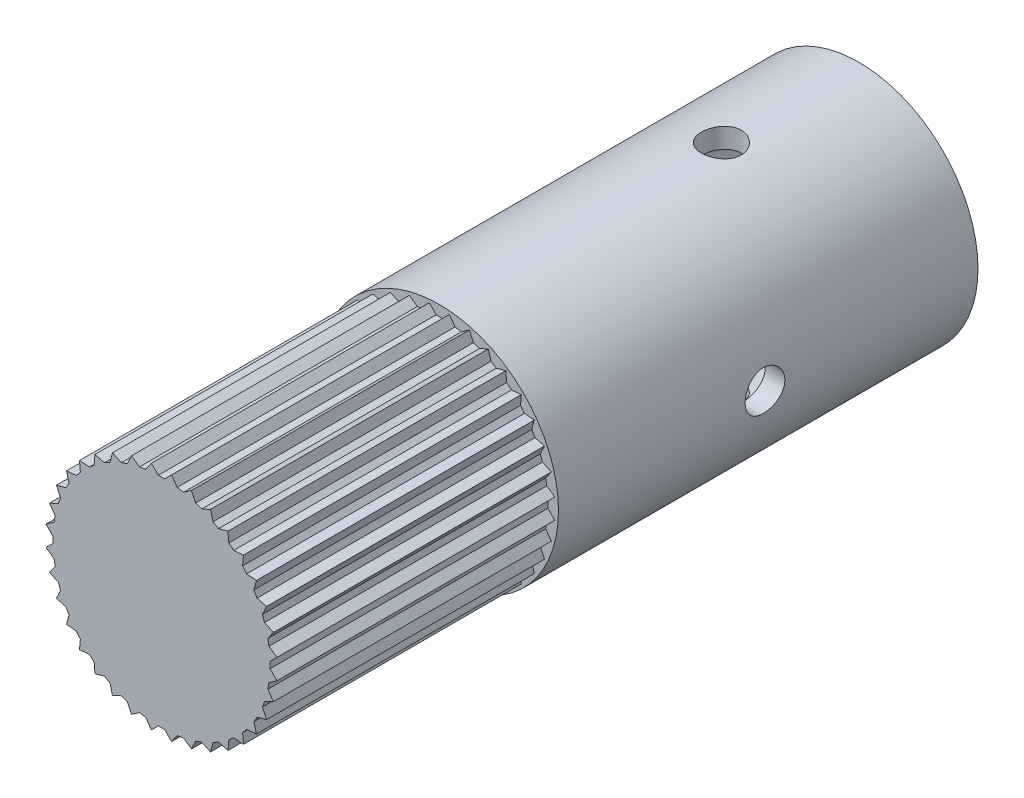
from build123d import *

# Parameters (mm, degrees)
SKETCH5_W               = 1.587499994
SKETCH5_H               = 55.780081988
SKETCH7_R               = 1.5875
CUT_EXTRUDE5_DEPTH      = 10.524999994
CUT_EXTRUDE5_DEPTH_BACK = 10.524999994
SKETCH6_R               = 1.5875
CUT_EXTRUDE6_DEPTH      = 10.525000094
CUT_EXTRUDE6_DEPTH_BACK = 10.525000094
CUT_EXTRUDE7_START      = 77.941582
SKETCH8_R               = 12.7
CUT_EXTRUDE7_DEPTH      = 22.225
SKETCH10_R              = 7.9375
BOSS_EXTRUDE1_DEPTH     = 30.380082


with BuildPart() as part:
    # Sketch5 → Revolve2 (revolve)
    with BuildSketch(Plane(origin=(0, 0, 0), x_dir=(1, 0, 0), z_dir=(0, 1, 0))):
        with Locations((8.731249997, -50.051540994)):
            Rectangle(SKETCH5_W, SKETCH5_H)
    revolve(axis=Axis((0, 0, 0), (0, 0, 1)))

    # Sketch7 → Cut-Extrude5 (cut, two sides)
    with BuildSketch(Plane(origin=(0, 0, 0), x_dir=(0, 0, -1), z_dir=(1, 0, 0))) as cut_extrude5_sk:
        with Locations((-39.195999993, 0)):
            Circle(SKETCH7_R)
    extrude(amount=CUT_EXTRUDE5_DEPTH, mode=Mode.SUBTRACT)
    extrude(cut_extrude5_sk.sketch, amount=-CUT_EXTRUDE5_DEPTH_BACK, mode=Mode.SUBTRACT)

    # Sketch6 → Cut-Extrude6 (cut, two sides)
    with BuildSketch(Plane(origin=(0, 0, 0), x_dir=(1, 0, 0), z_dir=(0, 1, 0))) as cut_extrude6_sk:
        with Locations((1e-09, -33.163499999)):
            Circle(SKETCH6_R)
    extrude(amount=CUT_EXTRUDE6_DEPTH, mode=Mode.SUBTRACT)
    extrude(cut_extrude6_sk.sketch, amount=-CUT_EXTRUDE6_DEPTH_BACK, mode=Mode.SUBTRACT)

    # Sketch8 → Cut-Extrude7 (cut)
    with BuildSketch(Plane.XY.offset(CUT_EXTRUDE7_START)):
        Circle(SKETCH8_R)
        Polygon((9.235721046, -0.808020891), (8.681700155, -0.254), (8.681700155, 0.254), (9.235721046, 0.808020891), (8.593912259, 1.257420242), (8.505698985, 1.75770258), (8.955098336, 2.399511367), (8.245002688, 2.730634406), (8.071256455, 3.207998257), (8.402379494, 3.918093905), (7.645572882, 4.120879625), (7.391572882, 4.56082053), (7.594358603, 5.317627141), (6.813836213, 5.385914002), (6.487300108, 5.775064579), (6.555586968, 6.555586968), (5.775064579, 6.487300108), (5.385914002, 6.813836213), (5.317627141, 7.594358603), (4.56082053, 7.391572882), (4.120879625, 7.645572882), (3.918093905, 8.402379494), (3.207998257, 8.071256455), (2.730634406, 8.245002688), (2.399511367, 8.955098336), (1.75770258, 8.505698985), (1.257420242, 8.593912259), (0.808020891, 9.235721046), (0.254, 8.681700155), (-0.254, 8.681700155), (-0.808020891, 9.235721046), (-1.257420242, 8.593912259), (-1.75770258, 8.505698985), (-2.399511367, 8.955098336), (-2.730634406, 8.245002688), (-3.207998257, 8.071256455), (-3.918093905, 8.402379494), (-4.120879625, 7.645572882), (-4.56082053, 7.391572882), (-5.317627141, 7.594358603), (-5.385914002, 6.813836213), (-5.775064579, 6.487300108), (-6.555586968, 6.555586968), (-6.487300108, 5.775064579), (-6.813836213, 5.385914002), (-7.594358603, 5.317627141), (-7.391572882, 4.56082053), (-7.645572882, 4.120879625), (-8.402379494, 3.918093905), (-8.071256455, 3.207998257), (-8.245002688, 2.730634406), (-8.955098336, 2.399511367), (-8.505698985, 1.75770258), (-8.593912259, 1.257420242), (-9.235721046, 0.808020891), (-8.681700155, 0.254), (-8.681700155, -0.254), (-9.235721046, -0.808020891), (-8.593912259, -1.257420242), (-8.505698985, -1.75770258), (-8.955098336, -2.399511367), (-8.245002688, -2.730634406), (-8.071256455, -3.207998257), (-8.402379494, -3.918093905), (-7.645572882, -4.120879625), (-7.391572882, -4.56082053), (-7.594358603, -5.317627141), (-6.813836213, -5.385914002), (-6.487300108, -5.775064579), (-6.555586968, -6.555586968), (-5.775064579, -6.487300108), (-5.385914002, -6.813836213), (-5.317627141, -7.594358603), (-4.56082053, -7.391572882), (-4.120879625, -7.645572882), (-3.918093905, -8.402379494), (-3.207998257, -8.071256455), (-2.730634406, -8.245002688), (-2.399511367, -8.955098336), (-1.75770258, -8.505698985), (-1.257420242, -8.593912259), (-0.808020891, -9.235721046), (-0.254, -8.681700155), (0.254, -8.681700155), (0.808020891, -9.235721046), (1.257420242, -8.593912259), (1.75770258, -8.505698985), (2.399511367, -8.955098336), (2.730634406, -8.245002688), (3.207998257, -8.071256455), (3.918093905, -8.402379494), (4.120879625, -7.645572882), (4.56082053, -7.391572882), (5.317627141, -7.594358603), (5.385914002, -6.813836213), (5.775064579, -6.487300108), (6.555586968, -6.555586968), (6.487300108, -5.775064579), (6.813836213, -5.385914002), (7.594358603, -5.317627141), (7.391572882, -4.56082053), (7.645572882, -4.120879625), (8.402379494, -3.918093905), (8.071256455, -3.207998257), (8.245002688, -2.730634406), (8.955098336, -2.399511367), (8.505698985, -1.75770258), (8.593912259, -1.257420242), align=None, mode=Mode.SUBTRACT)
    extrude(amount=-CUT_EXTRUDE7_DEPTH, mode=Mode.SUBTRACT)

    # Sketch10 → Boss-Extrude1 (add)
    with BuildSketch(Plane(origin=(0, 0, 47.5615), x_dir=(-1, 0, 0), z_dir=(0, 0, -1))):
        Circle(SKETCH10_R)
    extrude(amount=-BOSS_EXTRUDE1_DEPTH)


solid = part.part
